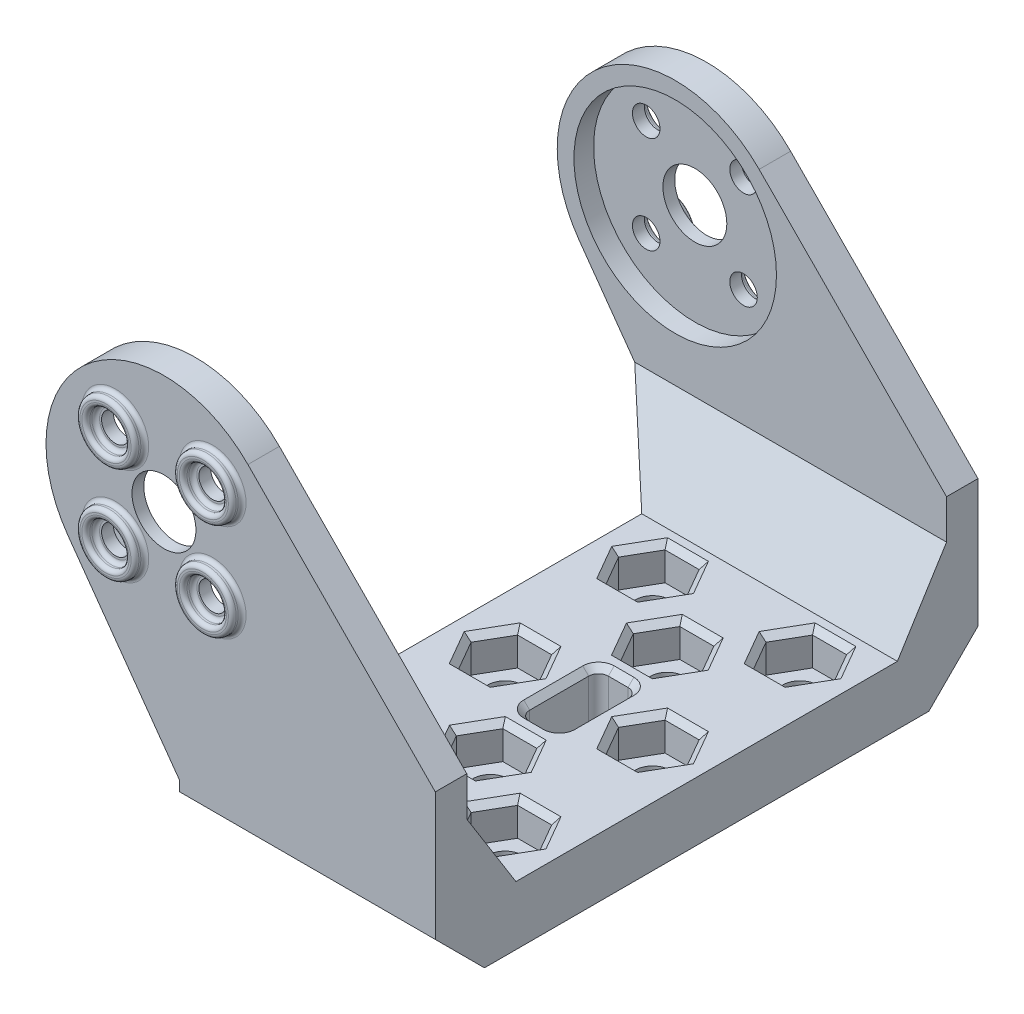
from build123d import *

# Parameters (mm, degrees)
SKETCH_1_R          = 3.25
SKETCH_1_R_2        = 1.4
EXTRUDE_1_DEPTH     = 3.2
SKETCH_2_W          = 26
SKETCH_2_H          = 6
EXTRUDE_2_DEPTH     = 48.8
SKETCH_3_R          = 1.4
SKETCH_3_R_2        = 3.25
EXTRUDE_3_DEPTH     = 3.2
SKETCH_4_R          = 10.3
CUT_EXTRUDE_1_DEPTH = 2
SKETCH_5_R          = 10.3
CUT_EXTRUDE_2_DEPTH = 2
CHAMFER_1_SIZE      = 5
SKETCH_6_R          = 3
SKETCH_6_R_2        = 2
EXTRUDE_4_DEPTH     = 1
SKETCH_7_R          = 3
SKETCH_7_R_2        = 2
EXTRUDE_5_DEPTH     = 1
FILLET_1_R          = 0.4
SKETCH_8_R          = 1.75
CUT_EXTRUDE_3_DEPTH = 6
CUT_EXTRUDE_4_DEPTH = 3.5
CHAMFER_4_SIZE      = 5
CHAMFER_4_SIZE2     = 8
CHAMFER_5_SIZE      = 8
CHAMFER_5_SIZE2     = 5
CHAMFER_6_SIZE      = 0.6


with BuildPart() as part:
    # Эскиз1 → Бобышка-Вытянуть1 (new body)
    with BuildSketch(Plane.XY):
        with BuildLine():
            Line((1.6, -28.877499952), (1.6, -22.877499952))
            Line((1.6, -22.877499952), (-9.76312524, -6.977204709))
            ThreePointArc((-9.76312524, -6.977204709), (-7.728004908, 9.180301745), (8.539885617, 8.43032346))
            Line((8.539885617, 8.43032346), (27.6, -10.877499952))
            Line((27.6, -10.877499952), (27.6, -28.877499952))
            Line((27.6, -28.877499952), (1.6, -28.877499952))
        make_face()
        Circle(SKETCH_1_R, mode=Mode.SUBTRACT)
        with Locations((-4.949747468, 4.949747468)):
            Circle(SKETCH_1_R_2, mode=Mode.SUBTRACT)
        with Locations((4.949747468, 4.949747468)):
            Circle(SKETCH_1_R_2, mode=Mode.SUBTRACT)
        with Locations((4.949747468, -4.949747468)):
            Circle(SKETCH_1_R_2, mode=Mode.SUBTRACT)
        with Locations((-4.949747468, -4.949747468)):
            Circle(SKETCH_1_R_2, mode=Mode.SUBTRACT)
    extrude(amount=EXTRUDE_1_DEPTH)

    # Эскиз2 → Бобышка-Вытянуть2 (add)
    with BuildSketch(Plane.XY.offset(3.2)):
        with Locations((14.6, -25.877499952)):
            Rectangle(SKETCH_2_W, SKETCH_2_H)
    extrude(amount=EXTRUDE_2_DEPTH)

    # Эскиз3 → Бобышка-Вытянуть3 (add)
    with BuildSketch(Plane.XY.offset(52)):
        with BuildLine():
            Line((1.6, -28.877499952), (27.6, -28.877499952))
            Line((27.6, -28.877499952), (27.6, -10.877499952))
            Line((27.6, -10.877499952), (8.539885617, 8.43032346))
            ThreePointArc((8.539885617, 8.43032346), (-7.728004908, 9.180301745), (-9.76312524, -6.977204709))
            Line((-9.76312524, -6.977204709), (1.6, -22.877499952))
            Line((1.6, -22.877499952), (1.6, -28.877499952))
        make_face()
        with Locations((-4.949747468, 4.949747468)):
            Circle(SKETCH_3_R, mode=Mode.SUBTRACT)
        Circle(SKETCH_3_R_2, mode=Mode.SUBTRACT)
        with Locations((-4.949747468, -4.949747468)):
            Circle(SKETCH_3_R, mode=Mode.SUBTRACT)
        with Locations((4.949747468, -4.949747468)):
            Circle(SKETCH_3_R, mode=Mode.SUBTRACT)
        with Locations((4.949747468, 4.949747468)):
            Circle(SKETCH_3_R, mode=Mode.SUBTRACT)
    extrude(amount=EXTRUDE_3_DEPTH)

    # Эскиз4 → Вырез-Вытянуть1 (cut)
    with BuildSketch(Plane.XY.offset(3.2)):
        Circle(SKETCH_4_R)
    extrude(amount=-CUT_EXTRUDE_1_DEPTH, mode=Mode.SUBTRACT)

    # Эскиз5 → Вырез-Вытянуть2 (cut)
    with BuildSketch(Plane(origin=(0, 0, 52), x_dir=(-1, 0, 0), z_dir=(0, 0, -1))):
        with Locations(Location((0, 0, 0), (0, 0, 180))):
            Circle(SKETCH_5_R)
    extrude(amount=-CUT_EXTRUDE_2_DEPTH, mode=Mode.SUBTRACT)

    # Фаска1
    chamfer_1_edges = [part.edges().sort_by_distance(p)[0] for p in [
        (14.6, -28.877499952, 55.2),
        (14.6, -28.877499952, 0),
    ]]
    chamfer(chamfer_1_edges, length=CHAMFER_1_SIZE)

    # Эскиз6 → Бобышка-Вытянуть4 (add)
    with BuildSketch(Plane.XY.offset(55.2)):
        with Locations((-4.949747468, 4.949747468)):
            Circle(SKETCH_6_R)
        with Locations((-4.949747468, 4.949747468)):
            Circle(SKETCH_6_R_2, mode=Mode.SUBTRACT)
        with Locations((4.949747468, -4.949747468)):
            Circle(SKETCH_6_R)
        with Locations((4.949747468, -4.949747468)):
            Circle(SKETCH_6_R_2, mode=Mode.SUBTRACT)
        with Locations((-4.949747468, -4.949747468)):
            Circle(SKETCH_6_R)
        with Locations((-4.949747468, -4.949747468)):
            Circle(SKETCH_6_R_2, mode=Mode.SUBTRACT)
        with Locations((4.949747468, 4.949747468)):
            Circle(SKETCH_6_R)
        with Locations((4.949747468, 4.949747468)):
            Circle(SKETCH_6_R_2, mode=Mode.SUBTRACT)
    extrude(amount=EXTRUDE_4_DEPTH)

    # Эскиз7 → Бобышка-Вытянуть5 (add)
    with BuildSketch(Plane(origin=(0, 0, 0), x_dir=(-1, 0, 0), z_dir=(0, 0, -1))):
        with Locations(Location((4.949747468, -4.949747468, 0), (0, 0, 180))):
            Circle(SKETCH_7_R)
        with Locations(Location((4.949747468, -4.949747468, 0), (0, 0, 180))):
            Circle(SKETCH_7_R_2, mode=Mode.SUBTRACT)
        with Locations(Location((4.949747468, 4.949747468, 0), (0, 0, 180))):
            Circle(SKETCH_7_R)
        with Locations(Location((4.949747468, 4.949747468, 0), (0, 0, 180))):
            Circle(SKETCH_7_R_2, mode=Mode.SUBTRACT)
        with Locations(Location((-4.949747468, 4.949747468, 0), (0, 0, 180))):
            Circle(SKETCH_7_R)
        with Locations(Location((-4.949747468, 4.949747468, 0), (0, 0, 180))):
            Circle(SKETCH_7_R_2, mode=Mode.SUBTRACT)
        with Locations(Location((-4.949747468, -4.949747468, 0), (0, 0, 180))):
            Circle(SKETCH_7_R)
        with Locations(Location((-4.949747468, -4.949747468, 0), (0, 0, 180))):
            Circle(SKETCH_7_R_2, mode=Mode.SUBTRACT)
    extrude(amount=EXTRUDE_5_DEPTH)

    # Скругление1
    fillet_1_edges = [part.edges().sort_by_distance(p)[0] for p in [
        (-6.949747468, 4.949747468, 55.2),
        (-7.949747468, 4.949747468, 56.2),
        (-7.949747468, 4.949747468, 55.2),
        (-6.949747468, 4.949747468, 56.2),
        (2.949747468, -4.949747468, 55.2),
        (1.949747468, -4.949747468, 56.2),
        (1.949747468, -4.949747468, 55.2),
        (2.949747468, -4.949747468, 56.2),
        (-6.949747468, -4.949747468, 55.2),
        (-7.949747468, -4.949747468, 56.2),
        (-7.949747468, -4.949747468, 55.2),
        (-6.949747468, -4.949747468, 56.2),
        (2.949747468, 4.949747468, 55.2),
        (1.949747468, 4.949747468, 56.2),
        (1.949747468, 4.949747468, 55.2),
        (2.949747468, 4.949747468, 56.2),
        (-7.949747468, -4.949747468, 0),
        (-7.949747468, -4.949747468, -1),
        (-6.949747468, -4.949747468, 0),
        (-6.949747468, -4.949747468, -1),
        (-7.949747468, 4.949747468, 0),
        (-7.949747468, 4.949747468, -1),
        (-6.949747468, 4.949747468, 0),
        (-6.949747468, 4.949747468, -1),
        (1.949747468, 4.949747468, 0),
        (1.949747468, 4.949747468, -1),
        (2.949747468, 4.949747468, 0),
        (2.949747468, 4.949747468, -1),
        (1.949747468, -4.949747468, 0),
        (1.949747468, -4.949747468, -1),
        (2.949747468, -4.949747468, 0),
        (2.949747468, -4.949747468, -1),
    ]]
    fillet(fillet_1_edges, radius=FILLET_1_R)

    # Эскиз8 → Вырез-Вытянуть3 (cut)
    with BuildSketch(Plane(origin=(0, -22.877499952, 0), x_dir=(1, 0, 0), z_dir=(0, 1, 0))):
        with Locations(Location((7.1, -12.6, 0), (0, 0, 270))):
            Circle(SKETCH_8_R)
        with Locations(Location((22.1, -12.6, 0), (0, 0, 270))):
            Circle(SKETCH_8_R)
        with Locations(Location((22.1, -42.6, 0), (0, 0, 270))):
            Circle(SKETCH_8_R)
        with Locations(Location((7.1, -42.6, 0), (0, 0, 270))):
            Circle(SKETCH_8_R)
        with Locations(Location((22.1, -27.6, 0), (0, 0, 270))):
            Circle(SKETCH_8_R)
        with Locations(Location((7.1, -27.6, 0), (0, 0, 270))):
            Circle(SKETCH_8_R)
        with Locations(Location((14.6, -18.6, 0), (0, 0, 270))):
            Circle(SKETCH_8_R)
        with Locations(Location((14.6, -36.6, 0), (0, 0, 270))):
            Circle(SKETCH_8_R)
        with BuildLine():
            Line((13.6, -31.6), (15.6, -31.6))
            ThreePointArc((15.6, -31.6), (16.307106781, -31.307106781), (16.6, -30.6))
            Line((16.6, -30.6), (16.6, -24.6))
            ThreePointArc((16.6, -24.6), (16.307106781, -23.892893219), (15.6, -23.6))
            Line((15.6, -23.6), (13.6, -23.6))
            ThreePointArc((13.6, -23.6), (12.892893219, -23.892893219), (12.6, -24.6))
            Line((12.6, -24.6), (12.6, -30.6))
            ThreePointArc((12.6, -30.6), (12.892893219, -31.307106781), (13.6, -31.6))
        make_face()
    extrude(amount=-CUT_EXTRUDE_3_DEPTH, mode=Mode.SUBTRACT)

    # Эскиз9 → Вырез-Вытянуть4 (cut)
    with BuildSketch(Plane(origin=(0, -22.877499952, 0), x_dir=(1, 0, 0), z_dir=(0, 1, 0))):
        Polygon((10.564101615, -12.6), (8.832050808, -9.6), (5.367949192, -9.6), (3.635898385, -12.6), (5.367949192, -15.6), (8.832050808, -15.6), align=None)
        Polygon((18.635898385, -12.6), (20.367949192, -15.6), (23.832050808, -15.6), (25.564101615, -12.6), (23.832050808, -9.6), (20.367949192, -9.6), align=None)
        Polygon((18.064101615, -18.6), (16.332050808, -15.6), (12.867949192, -15.6), (11.135898385, -18.6), (12.867949192, -21.6), (16.332050808, -21.6), align=None)
        Polygon((10.564101615, -27.6), (8.832050808, -24.6), (5.367949192, -24.6), (3.635898385, -27.6), (5.367949192, -30.6), (8.832050808, -30.6), align=None)
        Polygon((18.635898385, -27.6), (20.367949192, -30.6), (23.832050808, -30.6), (25.564101615, -27.6), (23.832050808, -24.6), (20.367949192, -24.6), align=None)
        Polygon((18.064101615, -36.6), (16.332050808, -33.6), (12.867949192, -33.6), (11.135898385, -36.6), (12.867949192, -39.6), (16.332050808, -39.6), align=None)
        Polygon((18.635898385, -42.6), (20.367949192, -45.6), (23.832050808, -45.6), (25.564101615, -42.6), (23.832050808, -39.6), (20.367949192, -39.6), align=None)
        Polygon((10.564101615, -42.6), (8.832050808, -39.6), (5.367949192, -39.6), (3.635898385, -42.6), (5.367949192, -45.6), (8.832050808, -45.6), align=None)
    extrude(amount=-CUT_EXTRUDE_4_DEPTH, mode=Mode.SUBTRACT)

    # Фаска4
    chamfer_4_edges = [part.edges().sort_by_distance(p)[0] for p in [
        (14.6, -22.877499952, 3.2),
    ]]
    chamfer_4_side = [part.faces().sort_by_distance(p)[0] for p in [
        (2.152941227, -22.877499952, 27.6),
    ]]
    chamfer(chamfer_4_edges, length=CHAMFER_4_SIZE, length2=CHAMFER_4_SIZE2, reference=chamfer_4_side[0])

    # Фаска5
    chamfer_5_edges = [part.edges().sort_by_distance(p)[0] for p in [
        (14.6, -22.877499952, 52),
    ]]
    chamfer_5_side = [part.faces().sort_by_distance(p)[0] for p in [
        (10.958645697, -10.92055919, 52),
    ]]
    chamfer(chamfer_5_edges, length=CHAMFER_5_SIZE, length2=CHAMFER_5_SIZE2, reference=chamfer_5_side[0])

    # Фаска6
    chamfer_6_edges = [part.edges().sort_by_distance(p)[0] for p in [
        (16.307106781, -22.877499952, 31.307106781),
        (16.6, -22.877499952, 27.6),
        (16.307106781, -22.877499952, 23.892893219),
        (14.6, -22.877499952, 23.6),
        (12.892893219, -22.877499952, 23.892893219),
        (12.6, -22.877499952, 27.6),
        (12.892893219, -22.877499952, 31.307106781),
        (14.6, -22.877499952, 31.6),
        (9.698076211, -22.877499952, 14.1),
        (9.698076211, -22.877499952, 11.1),
        (7.1, -22.877499952, 9.6),
        (4.501923789, -22.877499952, 11.1),
        (4.501923789, -22.877499952, 14.1),
        (7.1, -22.877499952, 15.6),
        (19.501923789, -22.877499952, 11.1),
        (19.501923789, -22.877499952, 14.1),
        (22.1, -22.877499952, 15.6),
        (24.698076211, -22.877499952, 14.1),
        (24.698076211, -22.877499952, 11.1),
        (22.1, -22.877499952, 9.6),
        (17.198076211, -22.877499952, 20.1),
        (17.198076211, -22.877499952, 17.1),
        (14.6, -22.877499952, 15.6),
        (12.001923789, -22.877499952, 17.1),
        (12.001923789, -22.877499952, 20.1),
        (14.6, -22.877499952, 21.6),
        (9.698076211, -22.877499952, 29.1),
        (9.698076211, -22.877499952, 26.1),
        (7.1, -22.877499952, 24.6),
        (4.501923789, -22.877499952, 26.1),
        (4.501923789, -22.877499952, 29.1),
        (7.1, -22.877499952, 30.6),
        (19.501923789, -22.877499952, 26.1),
        (19.501923789, -22.877499952, 29.1),
        (22.1, -22.877499952, 30.6),
        (24.698076211, -22.877499952, 29.1),
        (24.698076211, -22.877499952, 26.1),
        (22.1, -22.877499952, 24.6),
        (17.198076211, -22.877499952, 38.1),
        (17.198076211, -22.877499952, 35.1),
        (14.6, -22.877499952, 33.6),
        (12.001923789, -22.877499952, 35.1),
        (12.001923789, -22.877499952, 38.1),
        (14.6, -22.877499952, 39.6),
        (19.501923789, -22.877499952, 41.1),
        (19.501923789, -22.877499952, 44.1),
        (22.1, -22.877499952, 45.6),
        (24.698076211, -22.877499952, 44.1),
        (24.698076211, -22.877499952, 41.1),
        (22.1, -22.877499952, 39.6),
        (9.698076211, -22.877499952, 44.1),
        (9.698076211, -22.877499952, 41.1),
        (7.1, -22.877499952, 39.6),
        (4.501923789, -22.877499952, 41.1),
        (4.501923789, -22.877499952, 44.1),
        (7.1, -22.877499952, 45.6),
    ]]
    chamfer(chamfer_6_edges, length=CHAMFER_6_SIZE)


solid = part.part
